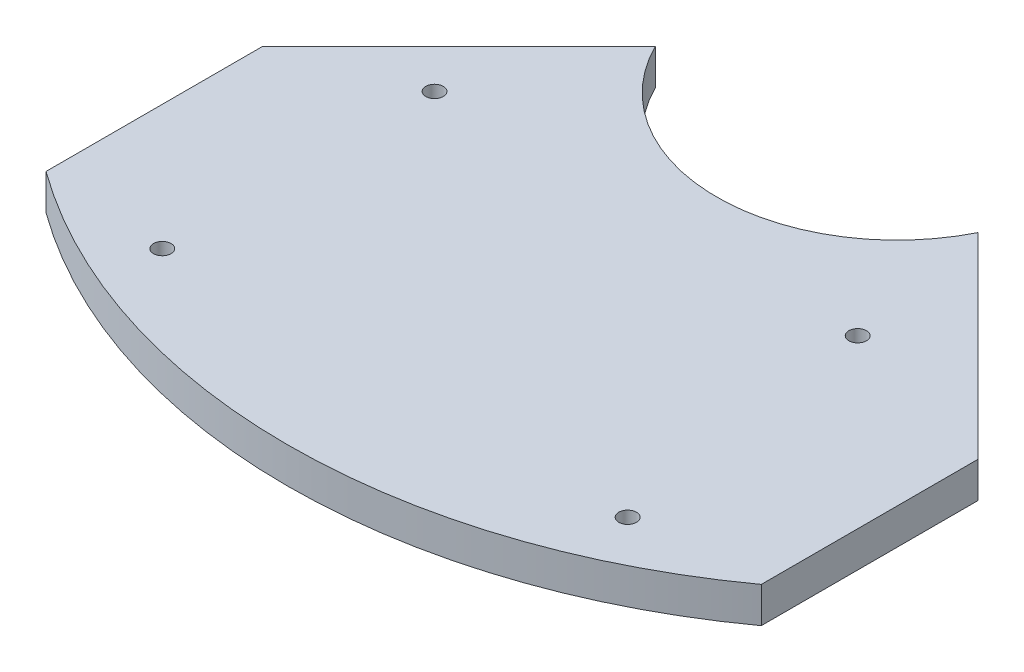
from build123d import *

# Parameters (mm, degrees)
BOSS_EXTRUDE1_DEPTH = 6.35
SKETCH3_R           = 1.5621
CUT_EXTRUDE1_DEPTH  = 7.35


with BuildPart() as part:
    # Sketch1 → Boss-Extrude1 (new body)
    with BuildSketch(Plane(origin=(0, 0, 0), x_dir=(1, 0, 0), z_dir=(0, 1, 0))):
        with BuildLine():
            Line((-63.5, 59.072409794), (-63.5, 20.592039538))
            ThreePointArc((-63.5, 20.592039538), (-33.377694994, 5.276670816), (0, 0))
            Line((0, 0), (0, 76.2))
            ThreePointArc((0, 76.2), (-16.843183971, 80.990709686), (-28.643822974, 93.92858682))
            Line((-28.643822974, 93.92858682), (-63.5, 59.072409794))
        make_face()
    boss_extrude1 = extrude(amount=BOSS_EXTRUDE1_DEPTH)

    # Mirror1: Boss-Extrude1 across plane
    add(boss_extrude1.mirror(Plane(origin=(0, 0, 0), x_dir=(0, 0, 1), z_dir=(1, 0, 0))))

    # Sketch3 → Cut-Extrude1 (cut, through all)
    with BuildSketch(Plane(origin=(0, 6.35, 0), x_dir=(1, 0, 0), z_dir=(0, 1, 0))):
        with Locations((-41.3131, 19.05)):
            Circle(SKETCH3_R)
        with Locations((41.3131, 19.05)):
            Circle(SKETCH3_R)
        with Locations((-41.3131, 67.3862)):
            Circle(SKETCH3_R)
        with Locations((33.8201, 67.3862)):
            Circle(SKETCH3_R)
    extrude(amount=-CUT_EXTRUDE1_DEPTH, mode=Mode.SUBTRACT)


solid = part.part
